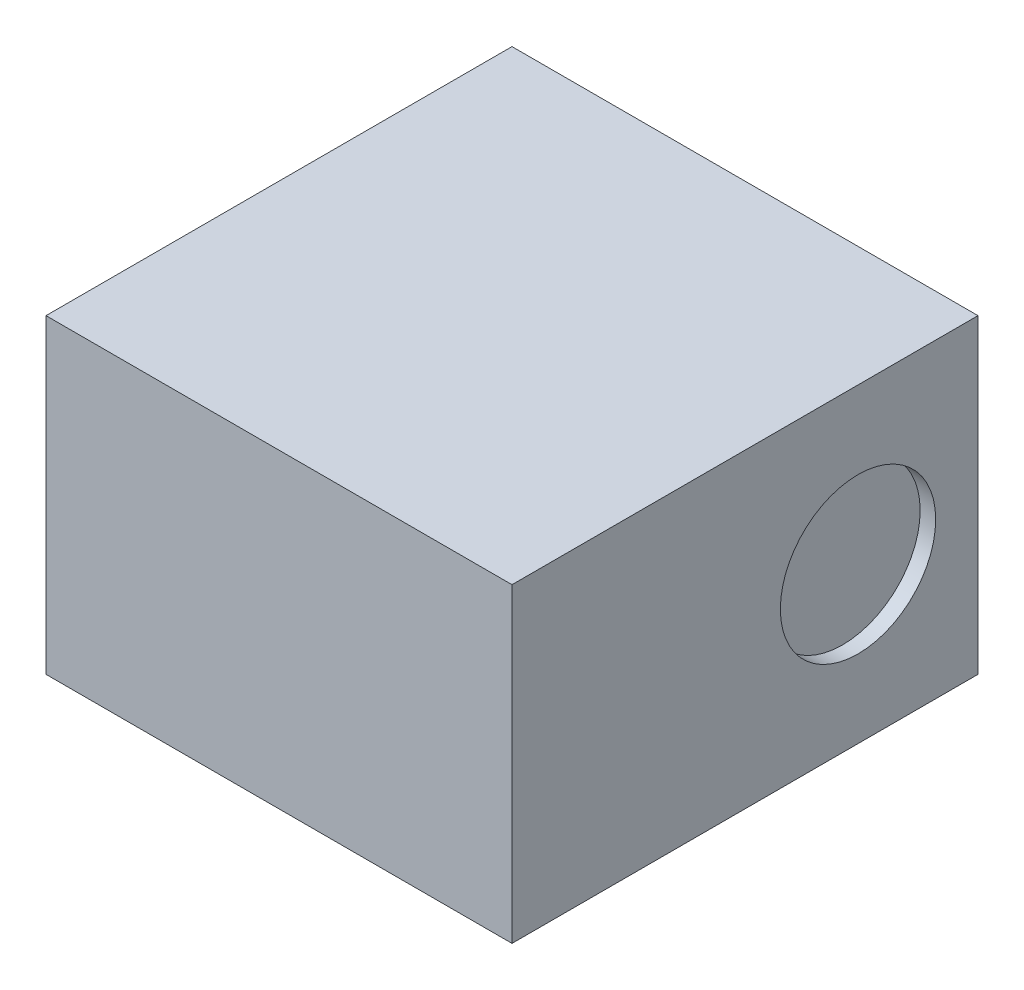
from build123d import *

# Parameters (mm, degrees)
SKETCH1_W           = 1.5
SKETCH1_H           = 1.5
BOSS_EXTRUDE1_DEPTH = 1
SKETCH2_R           = 0.25
CUT_EXTRUDE1_DEPTH  = 0.05


with BuildPart() as part:
    # Sketch1 → Boss-Extrude1 (new body)
    with BuildSketch(Plane(origin=(0, 0, 0), x_dir=(1, 0, 0), z_dir=(0, 1, 0))):
        Rectangle(SKETCH1_W, SKETCH1_H)
    extrude(amount=BOSS_EXTRUDE1_DEPTH)

    # Sketch2 → Cut-Extrude1 (cut)
    with BuildSketch(Plane(origin=(0.75, 0, 0), x_dir=(0, 0, -1), z_dir=(1, 0, 0))):
        with Locations((0.363809966, 0.5)):
            Circle(SKETCH2_R)
    extrude(amount=-CUT_EXTRUDE1_DEPTH, mode=Mode.SUBTRACT)


solid = part.part
